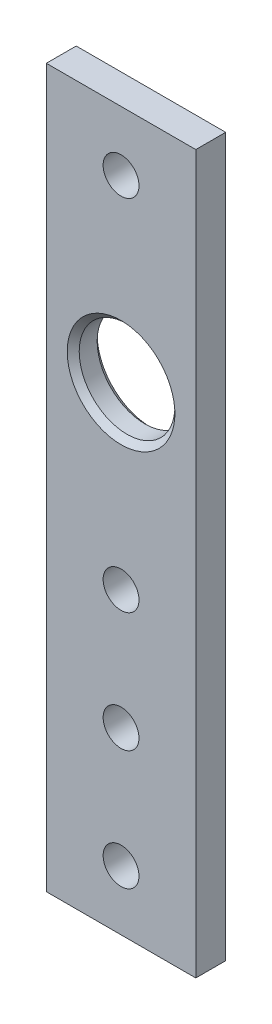
from build123d import *

# Parameters (mm, degrees)
SKETCH1_W           = 25
SKETCH1_H           = 120
SKETCH1_R           = 3
SKETCH1_R_2         = 8
BOSS_EXTRUDE1_DEPTH = 5
CHAMFER1_SIZE       = 1


with BuildPart() as part:
    # Sketch1 → Boss-Extrude1 (new body)
    with BuildSketch(Plane.XY):
        with Locations((12.5, 60)):
            Rectangle(SKETCH1_W, SKETCH1_H)
        with Locations((12.5, 110)):
            Circle(SKETCH1_R, mode=Mode.SUBTRACT)
        with Locations((12.5, 80)):
            Circle(SKETCH1_R_2, mode=Mode.SUBTRACT)
        with Locations((12.5, 50)):
            Circle(SKETCH1_R, mode=Mode.SUBTRACT)
        with Locations((12.5, 30)):
            Circle(SKETCH1_R, mode=Mode.SUBTRACT)
        with Locations((12.5, 10)):
            Circle(SKETCH1_R, mode=Mode.SUBTRACT)
    extrude(amount=BOSS_EXTRUDE1_DEPTH)

    # Chamfer1
    chamfer1_edges = [part.edges().sort_by_distance(p)[0] for p in [
        (4.5, 80, 0),
        (4.5, 80, 5),
    ]]
    chamfer(chamfer1_edges, length=CHAMFER1_SIZE)


solid = part.part
